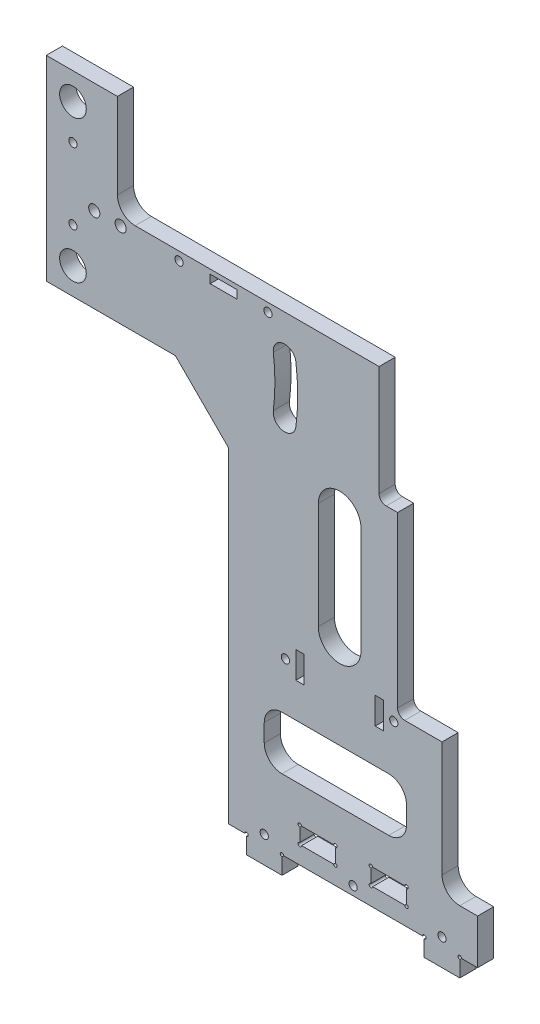
from build123d import *

# Parameters (mm, degrees)
SKETCH1_W                        = 12.7
SKETCH1_H                        = 6.0198
BOSS_EXTRUDE1_DEPTH              = 5.7658
SKETCH13_R                       = 0.635
CUT_EXTRUDE2_DEPTH               = 5.7658
CHAMFER1_SIZE                    = 50.8
F_4_CLEARANCE_HOLE1_D            = 2.9464
F_4_CLEARANCE_HOLE1_DEPTH        = 6.35
F_4_CLEARANCE_HOLE1_TIP          = 0.885187864
F_3_8_0_375_DIAMETER_HOLE1_D     = 9.525
F_3_8_0_375_DIAMETER_HOLE1_DEPTH = 6.35
F_3_8_0_375_DIAMETER_HOLE1_TIP   = 2.861598698
CUT_EXTRUDE3_REACH               = 234.708
FILLET3_R                        = 6.35
CUT_EXTRUDE4_REACH               = 234.708
CUT_EXTRUDE5_REACH               = 234.708
SKETCH26_W                       = 2.9591
SKETCH26_H                       = 9.525
CUT_EXTRUDE6_REACH               = 234.708
SKETCH29_W                       = 65.024
SKETCH29_H                       = 36.83
FILLET5_R                        = 6.35
CUT_EXTRUDE9_REACH               = 234.708
SKETCH32_W                       = 9.525
SKETCH32_H                       = 2.9591
CUT_EXTRUDE10_REACH              = 234.708
CHAMFER2_SIZE                    = 19.05
CUT_EXTRUDE11_START              = -5.7658
CUT_EXTRUDE11_DEPTH              = 5.7658
CUT_EXTRUDE12_REACH              = 234.708
SKETCH36_W                       = 57.277
SKETCH36_H                       = 36.83
FILLET7_R                        = 2.54
FILLET8_R                        = 6.35
CUT_EXTRUDE13_REACH              = 234.708
SKETCH37_W                       = 9.525
SKETCH37_H                       = 2.9591
F_4_CLEARANCE_HOLE2_D            = 2.9464
F_4_CLEARANCE_HOLE2_DEPTH        = 5.7658
SKETCH38_W                       = 50.8
SKETCH38_H                       = 19.05
CUT_EXTRUDE14_DEPTH              = 233.70795425
FILLET9_R                        = 6.35
TAP_DRILL_FOR_4_HELICOIL1_D      = 3.9878


with BuildPart() as part:
    # Sketch1 → Boss-Extrude1 (new body)
    with BuildSketch(Plane.XY):
        Polygon((-25.4, 0), (25.4, 0), (25.4, -6.35), (38.1, -6.35), (38.1, 0), (44.45, 0), (44.45, 205.2008), (-109.601, 205.2008), (-109.601, 135.3508), (-44.45, 135.3508), (-44.45, 0), (-38.1, 0), (-38.1, -6.35), (-25.4, -6.35), align=None)
        with Locations((12.7, 9.3599)):
            Rectangle(SKETCH1_W, SKETCH1_H, mode=Mode.SUBTRACT)
        with Locations((-12.7, 9.3599)):
            Rectangle(SKETCH1_W, SKETCH1_H, mode=Mode.SUBTRACT)
    extrude(amount=BOSS_EXTRUDE1_DEPTH)

    # Sketch13 → Cut-Extrude2 (cut)
    with BuildSketch(Plane.XY):
        with Locations((-19.05, 12.3698)):
            Circle(SKETCH13_R)
    cut_extrude2 = extrude(amount=CUT_EXTRUDE2_DEPTH, mode=Mode.SUBTRACT)

    # Sketch-Pattern1: Cut-Extrude2 at 11 more places
    with Locations((12.7, 0, 0), (12.7, -6.0198, 0), (0, -6.0198, 0), (25.4, 0, 0), (38.1, 0, 0), (38.1, -6.0198, 0), (25.4, -6.0198, 0), (57.15, -12.3698, 0), (44.45, -12.3698, 0), (-6.35, -12.3698, 0), (-19.05, -12.3698, 0)):
        add(cut_extrude2, mode=Mode.SUBTRACT)

    # Chamfer1
    chamfer1_edges = [part.edges().sort_by_distance(p)[0] for p in [
        (44.45, 205.2008, 2.8829),
    ]]
    chamfer(chamfer1_edges, length=CHAMFER1_SIZE)

    # 4 Clearance Hole1
    with Locations(Plane.XY.offset(5.7658)):
        with Locations((-31.75, 3.175), (31.75, 3.175), (0, 3.175)):
            Hole(F_4_CLEARANCE_HOLE1_D / 2, depth=F_4_CLEARANCE_HOLE1_DEPTH)
            with Locations((0, 0, -(F_4_CLEARANCE_HOLE1_DEPTH + F_4_CLEARANCE_HOLE1_TIP / 2))):  # 118° drill point
                Cone(0, F_4_CLEARANCE_HOLE1_D / 2, F_4_CLEARANCE_HOLE1_TIP, mode=Mode.SUBTRACT)

    # 3_8 _0.375_ Diameter Hole1
    with Locations(Plane.XY.offset(5.7658)):
        with Locations((-100.076, 144.8758), (-100.076, 195.6758)):
            Hole(F_3_8_0_375_DIAMETER_HOLE1_D / 2, depth=F_3_8_0_375_DIAMETER_HOLE1_DEPTH)
            with Locations((0, 0, -(F_3_8_0_375_DIAMETER_HOLE1_DEPTH + F_3_8_0_375_DIAMETER_HOLE1_TIP / 2))):  # 118° drill point
                Cone(0, F_3_8_0_375_DIAMETER_HOLE1_D / 2, F_3_8_0_375_DIAMETER_HOLE1_TIP, mode=Mode.SUBTRACT)

    # Sketch24 → Cut-Extrude3 (cut, up to next)
    with BuildSketch(Plane.XY.offset(5.7658), mode=Mode.PRIVATE) as cut_extrude3_sk1:
        Polygon((31.75, 167.1008), (31.75, 16.002), (44.45, 16.002), (44.45, 154.4008), align=None)
    cut_extrude3_tool1 = extrude(cut_extrude3_sk1.sketch, amount=-CUT_EXTRUDE3_REACH, mode=Mode.PRIVATE) & part.part
    add(cut_extrude3_tool1.solids().sort_by_distance((38.007144, 88.422828, 5.7658))[0], mode=Mode.SUBTRACT)

    # Fillet3
    fillet3_edges = [part.edges().sort_by_distance(p)[0] for p in [
        (31.75, 16.002, 2.8829),
    ]]
    fillet(fillet3_edges, radius=FILLET3_R)

    # Sketch25 → Cut-Extrude4 (cut, up to next)
    with BuildSketch(Plane.XY.offset(5.7658), mode=Mode.PRIVATE) as cut_extrude4_sk1:
        with BuildLine():
            ThreePointArc((-20.441531288, 134.8428), (-19.812, 144.8758), (-20.441531288, 154.9088))
            ThreePointArc((-20.441531288, 154.9088), (-24.981656286, 158.432924998), (-28.505781284, 153.8928))
            ThreePointArc((-28.505781284, 153.8928), (-27.94, 144.8758), (-28.505781284, 135.8588))
            ThreePointArc((-28.505781284, 135.8588), (-24.981656286, 131.318675002), (-20.441531288, 134.8428))
        make_face()
    cut_extrude4_tool1 = extrude(cut_extrude4_sk1.sketch, amount=-CUT_EXTRUDE4_REACH, mode=Mode.PRIVATE) & part.part
    # Sketch25 → Cut-Extrude4 (cut, up to next)
    with BuildSketch(Plane.XY.offset(5.7658), mode=Mode.PRIVATE) as cut_extrude4_sk2:
        with BuildLine():
            ThreePointArc((17.359640569, 130.0803), (18.288, 144.8758), (17.359640569, 159.6713))
            ThreePointArc((17.359640569, 159.6713), (12.819515571, 163.195424998), (9.295390572, 158.6553))
            ThreePointArc((9.295390572, 158.6553), (10.16, 144.8758), (9.295390572, 131.0963))
            ThreePointArc((9.295390572, 131.0963), (12.819515571, 126.556175002), (17.359640569, 130.0803))
        make_face()
    cut_extrude4_tool2 = extrude(cut_extrude4_sk2.sketch, amount=-CUT_EXTRUDE4_REACH, mode=Mode.PRIVATE) & part.part
    add(cut_extrude4_tool1.solids().sort_by_distance((-24.175106, 144.8758, 5.7658))[0], mode=Mode.SUBTRACT)
    add(cut_extrude4_tool2.solids().sort_by_distance((13.816141, 144.8758, 5.7658))[0], mode=Mode.SUBTRACT)

    # Sketch26 → Cut-Extrude5 (cut, up to next)
    with BuildSketch(Plane.XY.offset(5.7658), mode=Mode.PRIVATE) as cut_extrude5_sk1:
        with Locations((9.35355, 61.214)):
            Rectangle(SKETCH26_W, SKETCH26_H)
    cut_extrude5_tool1 = extrude(cut_extrude5_sk1.sketch, amount=-CUT_EXTRUDE5_REACH, mode=Mode.PRIVATE) & part.part
    # Sketch26 → Cut-Extrude5 (cut, up to next)
    with BuildSketch(Plane.XY.offset(5.7658), mode=Mode.PRIVATE) as cut_extrude5_sk2:
        with Locations((-19.00555, 61.214)):
            Rectangle(SKETCH26_W, SKETCH26_H)
    cut_extrude5_tool2 = extrude(cut_extrude5_sk2.sketch, amount=-CUT_EXTRUDE5_REACH, mode=Mode.PRIVATE) & part.part
    add(cut_extrude5_tool1.solids().sort_by_distance((9.35355, 61.214, 5.7658))[0], mode=Mode.SUBTRACT)
    add(cut_extrude5_tool2.solids().sort_by_distance((-19.00555, 61.214, 5.7658))[0], mode=Mode.SUBTRACT)

    # Sketch29 → Cut-Extrude6 (cut, up to next)
    with BuildSketch(Plane.XY.offset(5.7658), mode=Mode.PRIVATE) as cut_extrude6_sk1:
        with Locations((-0.762, 186.7858)):
            Rectangle(SKETCH29_W, SKETCH29_H)
    cut_extrude6_tool1 = extrude(cut_extrude6_sk1.sketch, amount=-CUT_EXTRUDE6_REACH, mode=Mode.PRIVATE) & part.part
    add(cut_extrude6_tool1.solids().sort_by_distance((-0.762, 186.7858, 5.7658))[0], mode=Mode.SUBTRACT)

    # Fillet5
    fillet5_edges = [part.edges().sort_by_distance(p)[0] for p in [
        (-33.274, 168.3708, 2.8829),
    ]]
    fillet(fillet5_edges, radius=FILLET5_R)

    # Sketch32 → Cut-Extrude9 (cut, up to next)
    with BuildSketch(Plane.XY.offset(5.7658), mode=Mode.PRIVATE) as cut_extrude9_sk1:
        with Locations((20.6375, 166.0975)):
            Rectangle(SKETCH32_W, SKETCH32_H)
    cut_extrude9_tool1 = extrude(cut_extrude9_sk1.sketch, amount=-CUT_EXTRUDE9_REACH, mode=Mode.PRIVATE) & part.part
    add(cut_extrude9_tool1.solids().sort_by_distance((20.6375, 166.0975, 5.7658))[0], mode=Mode.SUBTRACT)

    # Sketch31 → Cut-Extrude10 (cut, up to next)
    with BuildSketch(Plane.XY.offset(5.7658), mode=Mode.PRIVATE) as cut_extrude10_sk1:
        with BuildLine():
            Line((-12.446, 77.0763), (-12.446, 115.1763))
            ThreePointArc((-12.446, 115.1763), (-4.826, 122.7963), (2.794, 115.1763))
            Line((2.794, 115.1763), (2.794, 77.0763))
            ThreePointArc((2.794, 77.0763), (-4.826, 69.4563), (-12.446, 77.0763))
        make_face()
    cut_extrude10_tool1 = extrude(cut_extrude10_sk1.sketch, amount=-CUT_EXTRUDE10_REACH, mode=Mode.PRIVATE) & part.part
    add(cut_extrude10_tool1.solids().sort_by_distance((-4.826, 96.1263, 5.7658))[0], mode=Mode.SUBTRACT)

    # Chamfer2
    chamfer2_edges = [part.edges().sort_by_distance(p)[0] for p in [
        (-44.45, 135.3508, 2.8829),
    ]]
    chamfer(chamfer2_edges, length=CHAMFER2_SIZE)

    # Sketch35 → Cut-Extrude11 (cut)
    with BuildSketch(Plane.XY.offset(5.7658).offset(CUT_EXTRUDE11_START)):
        Polygon((31.75, 63.5), (15.875, 63.5), (15.875, 126.5243), (9.263515571, 126.5243), (9.263515571, 168.3708), (31.75, 168.3708), align=None)
    extrude(amount=CUT_EXTRUDE11_DEPTH, mode=Mode.SUBTRACT)

    # Sketch36 → Cut-Extrude12 (cut, up to next)
    with BuildSketch(Plane.XY.offset(5.7658), mode=Mode.PRIVATE) as cut_extrude12_sk1:
        with Locations((-55.5625, 186.7858)):
            Rectangle(SKETCH36_W, SKETCH36_H)
    cut_extrude12_tool1 = extrude(cut_extrude12_sk1.sketch, amount=-CUT_EXTRUDE12_REACH, mode=Mode.PRIVATE) & part.part
    add(cut_extrude12_tool1.solids().sort_by_distance((-55.5625, 186.7858, 5.7658))[0], mode=Mode.SUBTRACT)

    # Fillet7
    fillet7_edges = [part.edges().sort_by_distance(p)[0] for p in [
        (15.875, 63.5, 2.8829),
        (9.263515571, 126.5243, 2.8829),
    ]]
    fillet(fillet7_edges, radius=FILLET7_R)

    # Fillet8
    fillet8_edges = [part.edges().sort_by_distance(p)[0] for p in [
        (-84.201, 168.3708, 2.8829),
    ]]
    fillet(fillet8_edges, radius=FILLET8_R)

    # Sketch37 → Cut-Extrude13 (cut, up to next)
    with BuildSketch(Plane.XY.offset(5.7658), mode=Mode.PRIVATE) as cut_extrude13_sk1:
        with Locations((-46.298984429, 165.30375)):
            Rectangle(SKETCH37_W, SKETCH37_H)
    cut_extrude13_tool1 = extrude(cut_extrude13_sk1.sketch, amount=-CUT_EXTRUDE13_REACH, mode=Mode.PRIVATE) & part.part
    add(cut_extrude13_tool1.solids().sort_by_distance((-46.298984, 165.30375, 5.7658))[0], mode=Mode.SUBTRACT)

    # 4 Clearance Hole2
    with Locations(Plane.XY.offset(5.7658)):
        with Locations((-24.1681, 61.214), (14.5161, 61.214), (20.6375, 117.5708), (-100.076, 182.9758), (-100.076, 157.5758), (-62.173984429, 165.30375), (-30.423984429, 165.30375)):
            Hole(F_4_CLEARANCE_HOLE2_D / 2, depth=F_4_CLEARANCE_HOLE2_DEPTH)

    # Sketch38 → Cut-Extrude14 (cut, through all)
    with BuildSketch(Plane.XY.offset(5.7658)):
        with Locations((-6.35, 34.5948)):
            Rectangle(SKETCH38_W, SKETCH38_H)
    extrude(amount=-CUT_EXTRUDE14_DEPTH, mode=Mode.SUBTRACT)

    # Fillet9
    fillet9_edges = [part.edges().sort_by_distance(p)[0] for p in [
        (19.05, 44.1198, 2.8829),
        (19.05, 25.0698, 2.8829),
        (-31.75, 25.0698, 2.8829),
        (-31.75, 44.1198, 2.8829),
    ]]
    fillet(fillet9_edges, radius=FILLET9_R)

    # Tap Drill for _4 Helicoil1 (through all)
    with Locations(Plane.XY.offset(5.7658)):
        with Locations((-92.456, 165.7038), (-83.031, 165.7038)):
            Hole(TAP_DRILL_FOR_4_HELICOIL1_D / 2)


solid = part.part
